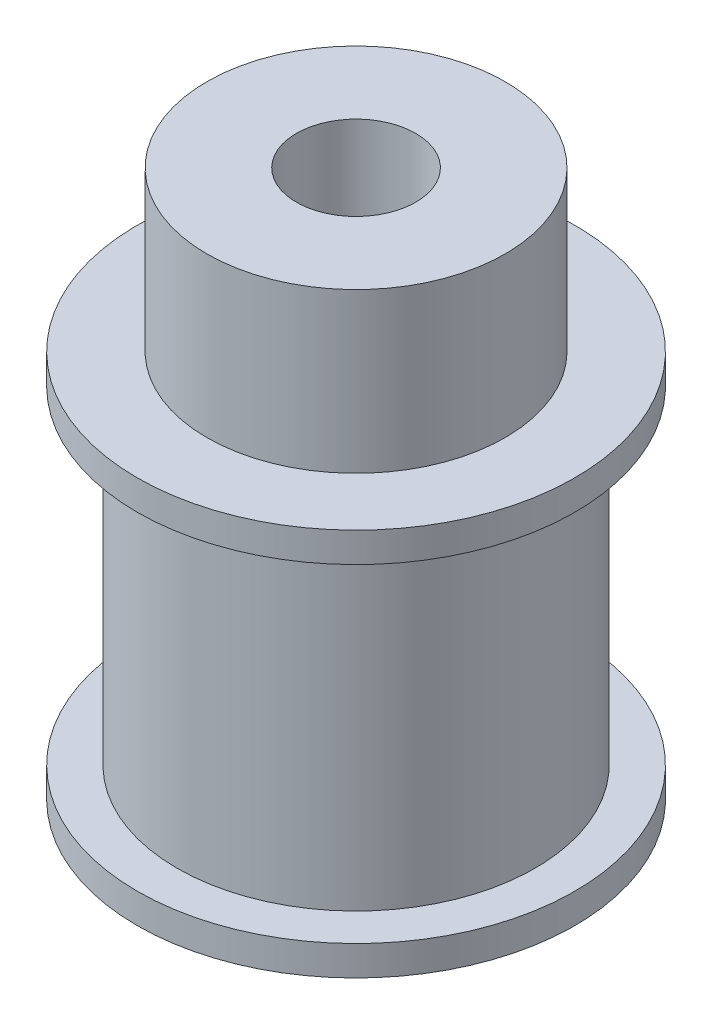
from build123d import *

# Parameters (mm, degrees)
SKETCH1_R           = 11
BOSS_EXTRUDE1_DEPTH = 1.5
SKETCH2_R           = 9
BOSS_EXTRUDE2_DEPTH = 16.5
BOSS_EXTRUDE3_START = 18
SKETCH1_2_R         = 11
BOSS_EXTRUDE3_DEPTH = 1.5
SKETCH3_R           = 7.5
BOSS_EXTRUDE4_DEPTH = 8
SKETCH4_R           = 3
CUT_EXTRUDE1_DEPTH  = 28.5


with BuildPart() as part:
    # Sketch1 → Boss-Extrude1 (new body)
    with BuildSketch(Plane(origin=(0, 0, 0), x_dir=(1, 0, 0), z_dir=(0, 1, 0))):
        Circle(SKETCH1_R)
    extrude(amount=BOSS_EXTRUDE1_DEPTH)

    # Sketch2 → Boss-Extrude2 (add)
    with BuildSketch(Plane(origin=(0, 1.5, 0), x_dir=(1, 0, 0), z_dir=(0, 1, 0))):
        Circle(SKETCH2_R)
    extrude(amount=BOSS_EXTRUDE2_DEPTH)

    # Sketch1_2 → Boss-Extrude3 (add)
    with BuildSketch(Plane(origin=(0, 0, 0), x_dir=(1, 0, 0), z_dir=(0, 1, 0)).offset(BOSS_EXTRUDE3_START)):
        Circle(SKETCH1_2_R)
    extrude(amount=BOSS_EXTRUDE3_DEPTH)

    # Sketch3 → Boss-Extrude4 (add)
    with BuildSketch(Plane(origin=(0, 19.5, 0), x_dir=(1, 0, 0), z_dir=(0, 1, 0))):
        Circle(SKETCH3_R)
    extrude(amount=BOSS_EXTRUDE4_DEPTH)

    # Sketch4 → Cut-Extrude1 (cut, through all)
    with BuildSketch(Plane.XZ):
        Circle(SKETCH4_R)
    extrude(amount=-CUT_EXTRUDE1_DEPTH, mode=Mode.SUBTRACT)


solid = part.part
